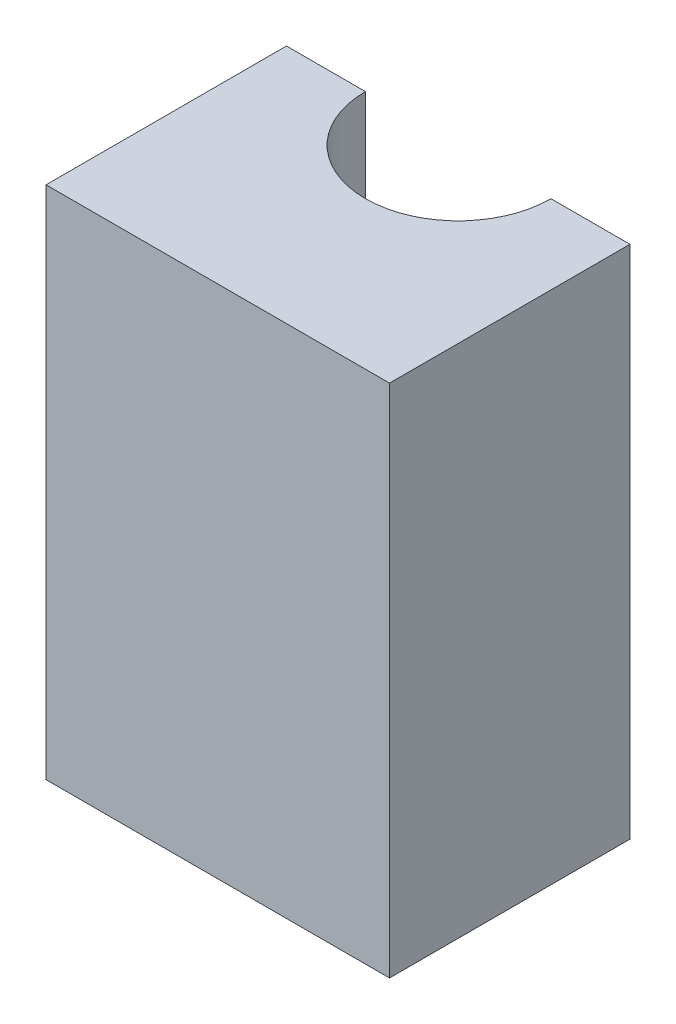
from build123d import *

# Parameters (mm, degrees)
BOSS_EXTRUDE1_DEPTH = 15


with BuildPart() as part:
    # Sketch1 → Boss-Extrude1 (new body)
    with BuildSketch(Plane(origin=(0, 0, 0), x_dir=(1, 0, 0), z_dir=(0, 1, 0))):
        with BuildLine():
            Line((2.7, 3.5), (5, 3.5))
            Line((5, 3.5), (5, -3.5))
            Line((5, -3.5), (-5, -3.5))
            Line((-5, -3.5), (-5, 3.5))
            Line((-5, 3.5), (-2.7, 3.5))
            ThreePointArc((-2.7, 3.5), (0, 0.8), (2.7, 3.5))
        make_face()
    extrude(amount=BOSS_EXTRUDE1_DEPTH)


solid = part.part
